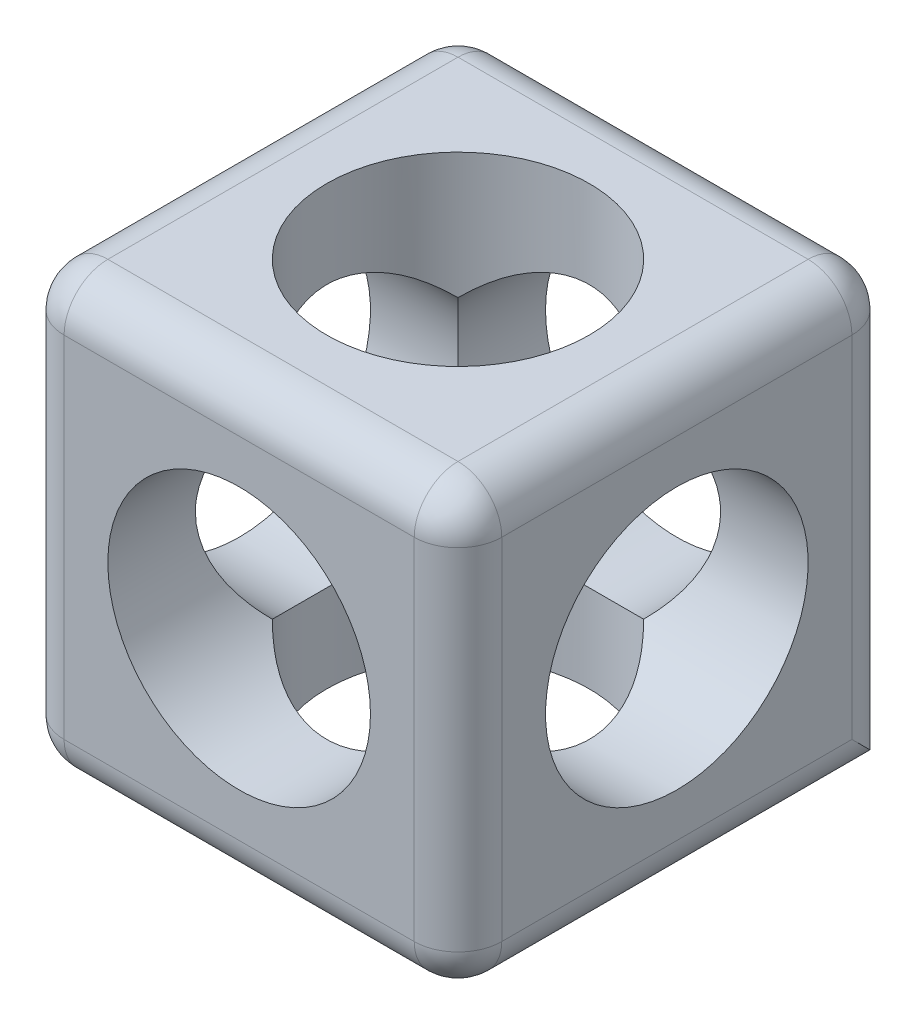
from build123d import *

# Parameters (mm, degrees)
ESQUISSE1_W             = 1
ESQUISSE1_H             = 1
BOSS_EXTRU_1_DEPTH      = 1
ESQUISSE2_R             = 0.3
ENL_V_MAT_EXTRU_1_DEPTH = 1
ESQUISSE4_R             = 0.3
ENL_V_MAT_EXTRU_2_DEPTH = 1
ESQUISSE3_R             = 0.3
ENL_V_MAT_EXTRU_3_DEPTH = 1
CONG_2_R                = 0.1
CONG_3_R                = 0.1


with BuildPart() as part:
    # Esquisse1 → Boss.-Extru.1 (new body)
    with BuildSketch(Plane.XY):
        with Locations((-0.5, 0.5)):
            Rectangle(ESQUISSE1_W, ESQUISSE1_H)
    extrude(amount=BOSS_EXTRU_1_DEPTH)

    # Esquisse2 → Enlèv. mat.-Extru.1 (cut)
    with BuildSketch(Plane(origin=(0, 0, 0), x_dir=(0, 0, -1), z_dir=(1, 0, 0))):
        with Locations((-0.5, 0.5)):
            Circle(ESQUISSE2_R)
    extrude(amount=-ENL_V_MAT_EXTRU_1_DEPTH, mode=Mode.SUBTRACT)

    # Esquisse4 → Enlèv. mat.-Extru.2 (cut)
    with BuildSketch(Plane(origin=(0, 0, 0), x_dir=(-1, 0, 0), z_dir=(0, 0, -1))):
        with Locations((0.5, 0.5)):
            Circle(ESQUISSE4_R)
    extrude(amount=-ENL_V_MAT_EXTRU_2_DEPTH, mode=Mode.SUBTRACT)

    # Esquisse3 → Enlèv. mat.-Extru.3 (cut)
    with BuildSketch(Plane(origin=(0, 1, 0), x_dir=(1, 0, 0), z_dir=(0, 1, 0))):
        with Locations((-0.5, -0.5)):
            Circle(ESQUISSE3_R)
    extrude(amount=-ENL_V_MAT_EXTRU_3_DEPTH, mode=Mode.SUBTRACT)

    # Congé2
    cong_2_edges = [part.edges().sort_by_distance(p)[0] for p in [
        (-1, 0.5, 1),
        (-0.5, 1, 1),
        (-1, 1, 0.5),
    ]]
    fillet(cong_2_edges, radius=CONG_2_R)

    # Congé3
    cong_3_edges = [part.edges().sort_by_distance(p)[0] for p in [
        (0, 0.45, 1),
        (-0.45, 0, 1),
        (0, 1, 0.45),
        (0, 0.970710678, 0.970710678),
        (-1, 0, 0.45),
        (-0.970710678, 0, 0.970710678),
        (-1, 0.45, 0),
        (-0.970710678, 0.970710678, 0),
        (-0.45, 1, 0),
        (0, 0.5, 0),
        (0, 0, 0.5),
    ]]
    fillet(cong_3_edges, radius=CONG_3_R)


solid = part.part
